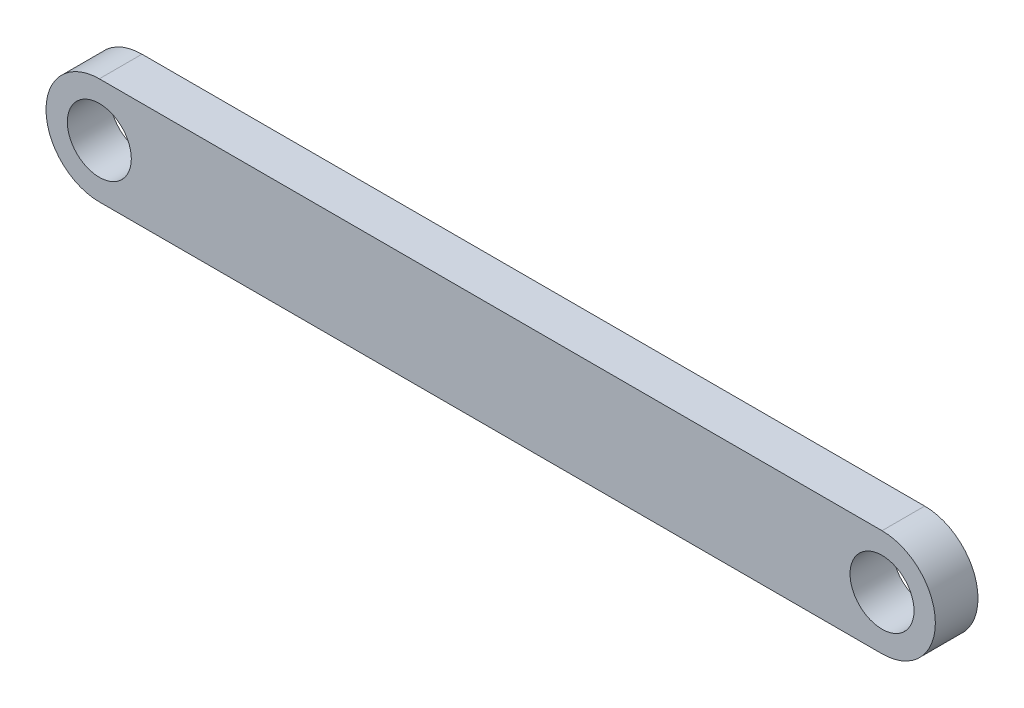
from build123d import *

# Parameters (mm, degrees)
SKETCH1_R           = 1.5
BOSS_EXTRUDE1_DEPTH = 2


with BuildPart() as part:
    # Sketch1 → Boss-Extrude1 (new body)
    with BuildSketch(Plane.XY):
        with BuildLine():
            Line((0.148728396, 2.529522743), (36.848728396, 2.529522743))
            ThreePointArc((36.848728396, 2.529522743), (39.348728396, 0.029522743), (36.848728396, -2.470477257))
            Line((36.848728396, -2.470477257), (0.148728396, -2.470477257))
            ThreePointArc((0.148728396, -2.470477257), (-2.351271604, 0.029522743), (0.148728396, 2.529522743))
        make_face()
        with Locations((0.148728396, 0.029522743)):
            Circle(SKETCH1_R, mode=Mode.SUBTRACT)
        with Locations((36.848728396, 0.029522743)):
            Circle(SKETCH1_R, mode=Mode.SUBTRACT)
    extrude(amount=BOSS_EXTRUDE1_DEPTH)


solid = part.part
